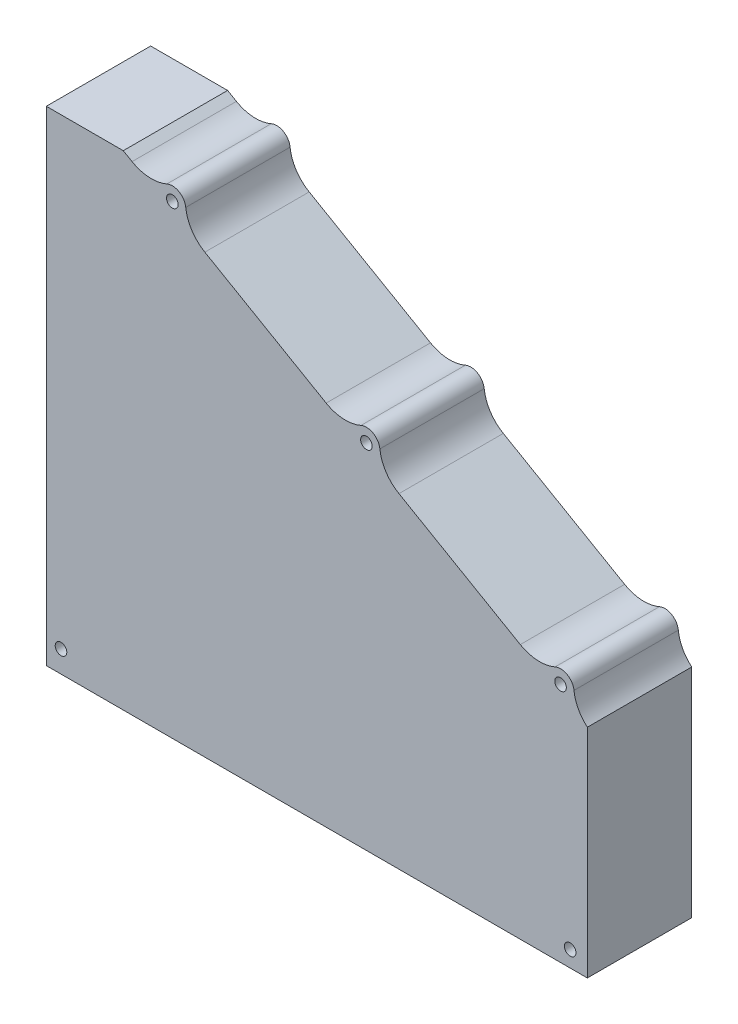
from build123d import *

# Parameters (mm, degrees)
SKETCH1_R           = 1.5
BOSS_EXTRUDE1_DEPTH = 25
SKETCH2_R           = 1.5
BOSS_EXTRUDE2_DEPTH = 2
SKETCH3_W           = 3
SKETCH3_H           = 17
CUT_EXTRUDE1_DEPTH  = 2
LPATTERN1_COUNT     = 7
LPATTERN1_PITCH     = 15


with BuildPart() as part:
    # Sketch1 → Boss-Extrude1 (new body)
    with BuildSketch(Plane.XY):
        with BuildLine():
            Line((-50.08587988, 100), (-70, 100))
            Line((-70, 100), (-70, -25.358547654))
            Line((-70, -25.358547654), (70, -25.358547654))
            Line((70, -25.358547654), (70, 30.840200363))
            ThreePointArc((70, 30.840200363), (67.647784394, 33.77119445), (66.543566366, 37.363456571))
            ThreePointArc((66.543566366, 37.363456571), (64.816659948, 40.011839547), (61.659897736, 40.187880739))
            ThreePointArc((61.659897736, 40.187880739), (57.09391383, 39.362702083), (52.647005809, 40.687140793))
            Line((52.647005809, 40.687140793), (21.252340591, 58.812859207))
            ThreePointArc((21.252340591, 58.812859207), (17.881889013, 62.001775167), (16.313522739, 66.368622551))
            ThreePointArc((16.313522739, 66.368622551), (14.584936491, 69.013139721), (11.430424316, 69.187880739))
            ThreePointArc((11.430424316, 69.187880739), (6.864440411, 68.362702083), (2.41753239, 69.687140793))
            Line((2.41753239, 69.687140793), (-28.977132828, 87.812859207))
            ThreePointArc((-28.977132828, 87.812859207), (-32.347584407, 91.001775167), (-33.915950681, 95.368622551))
            ThreePointArc((-33.915950681, 95.368622551), (-35.644536929, 98.013139721), (-38.799049103, 98.187880739))
            ThreePointArc((-38.799049103, 98.187880739), (-43.365033009, 97.362702083), (-47.81194103, 98.687140793))
            Line((-47.81194103, 98.687140793), (-50.08587988, 100))
        make_face()
        with BuildLine():
            Line((-50.621778265, 98), (68, 29.513684387))
            Line((68, 29.513684387), (68, -15.130655325))
            Line((68, -15.130655325), (51.241660417, -23.358547654))
            Line((51.241660417, -23.358547654), (-61.699771159, -23.358547654))
            Line((-61.699771159, -23.358547654), (-61.699771159, -19.718666382))
            ThreePointArc((-61.699771159, -19.718666382), (-63.017790644, -16.536685867), (-66.199771159, -15.218666382))
            Line((-66.199771159, -15.218666382), (-68, -15.218666382))
            Line((-68, -15.218666382), (-68, 98))
            Line((-68, 98), (-50.621778265, 98))
        make_face(mode=Mode.SUBTRACT)
        with Locations((63.06440991, 36.982050808)):
            Circle(SKETCH1_R, mode=Mode.SUBTRACT)
        with Locations((-37.394536929, 94.982050808)):
            Circle(SKETCH1_R, mode=Mode.SUBTRACT)
        with Locations((12.834936491, 65.982050808)):
            Circle(SKETCH1_R, mode=Mode.SUBTRACT)
        with Locations((65.552729719, -21.188668784)):
            Circle(SKETCH1_R, mode=Mode.SUBTRACT)
        with Locations((-66.199771159, -19.718666382)):
            Circle(SKETCH1_R, mode=Mode.SUBTRACT)
    extrude(amount=BOSS_EXTRUDE1_DEPTH)

    # Sketch2 → Boss-Extrude2 (add)
    with BuildSketch(Plane.XY.offset(25)):
        with BuildLine():
            Line((70, -25.358547654), (70, 30.840200363))
            ThreePointArc((70, 30.840200363), (67.647784394, 33.77119445), (66.543566366, 37.363456571))
            ThreePointArc((66.543566366, 37.363456571), (64.816659948, 40.011839547), (61.659897736, 40.187880739))
            ThreePointArc((61.659897736, 40.187880739), (57.09391383, 39.362702083), (52.647005809, 40.687140793))
            Line((52.647005809, 40.687140793), (21.252340591, 58.812859207))
            ThreePointArc((21.252340591, 58.812859207), (17.881889013, 62.001775167), (16.313522739, 66.368622551))
            ThreePointArc((16.313522739, 66.368622551), (14.584936491, 69.013139721), (11.430424316, 69.187880739))
            ThreePointArc((11.430424316, 69.187880739), (6.864440411, 68.362702083), (2.41753239, 69.687140793))
            Line((2.41753239, 69.687140793), (-28.977132828, 87.812859207))
            ThreePointArc((-28.977132828, 87.812859207), (-32.347584407, 91.001775167), (-33.915950681, 95.368622551))
            ThreePointArc((-33.915950681, 95.368622551), (-35.644536929, 98.013139721), (-38.799049103, 98.187880739))
            ThreePointArc((-38.799049103, 98.187880739), (-43.365033009, 97.362702083), (-47.81194103, 98.687140793))
            Line((-47.81194103, 98.687140793), (-50.08587988, 100))
            Line((-50.08587988, 100), (-70, 100))
            Line((-70, 100), (-70, -25.358547654))
            Line((-70, -25.358547654), (70, -25.358547654))
        make_face()
        with Locations((-37.394536929, 94.982050808)):
            Circle(SKETCH2_R, mode=Mode.SUBTRACT)
        with Locations((12.834936491, 65.982050808)):
            Circle(SKETCH2_R, mode=Mode.SUBTRACT)
        with Locations((63.06440991, 36.982050808)):
            Circle(SKETCH2_R, mode=Mode.SUBTRACT)
        with Locations((65.552729719, -21.188668784)):
            Circle(SKETCH2_R, mode=Mode.SUBTRACT)
        with Locations((-66.199771159, -19.718666382)):
            Circle(SKETCH2_R, mode=Mode.SUBTRACT)
    extrude(amount=BOSS_EXTRUDE2_DEPTH)

    # Sketch3 → Cut-Extrude1 (cut)
    with BuildSketch(Plane(origin=(0, -25.358547654, 0), x_dir=(-1, 0, 0), z_dir=(0, -1, 0))):
        with Locations((48.5, -13.5)):
            Rectangle(SKETCH3_W, SKETCH3_H)
    cut_extrude1 = extrude(amount=-CUT_EXTRUDE1_DEPTH, mode=Mode.SUBTRACT)

    # LPattern1: Cut-Extrude1 ×7
    with Locations(*[(i * LPATTERN1_PITCH, 0, 0) for i in range(1, LPATTERN1_COUNT)]):
        add(cut_extrude1, mode=Mode.SUBTRACT)


solid = part.part
